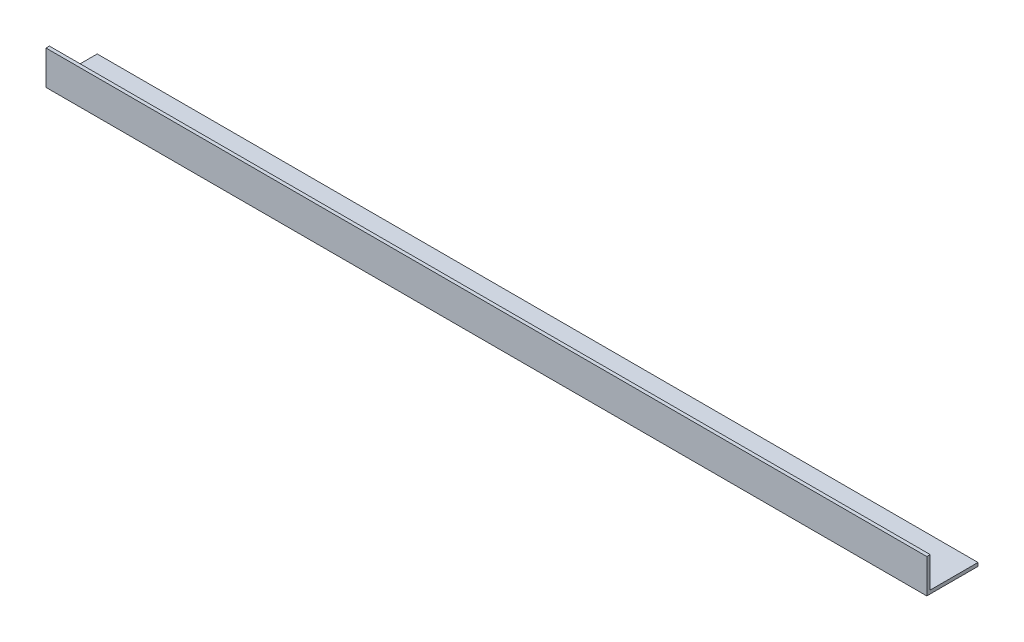
from build123d import *

# Parameters (mm, degrees)
SALIENTE_EXTRUIR1_DEPTH = 258


with BuildPart() as part:
    # Croquis1 → Saliente-Extruir1 (new body)
    with BuildSketch(Plane(origin=(0, 0, 0), x_dir=(0, 0, -1), z_dir=(1, 0, 0))):
        Polygon((0, 10), (0, 0), (15, 0), (15, 1), (1, 1), (1, 10), align=None)
    extrude(amount=SALIENTE_EXTRUIR1_DEPTH)


solid = part.part
